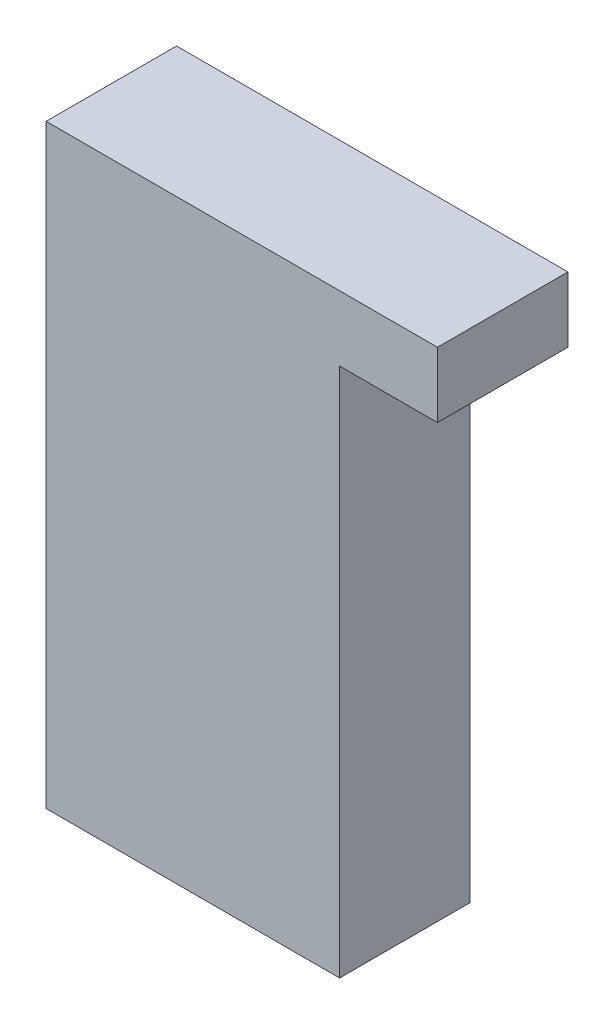
from build123d import *

# Parameters (mm, degrees)
SKETCH1_W           = 36
SKETCH1_H           = 16
BOSS_EXTRUDE1_DEPTH = 73
SKETCH2_W           = 16
SKETCH2_H           = 8
BOSS_EXTRUDE2_DEPTH = 12


with BuildPart() as part:
    # Sketch1 → Boss-Extrude1 (new body)
    with BuildSketch(Plane(origin=(0, 0, 0), x_dir=(1, 0, 0), z_dir=(0, 1, 0))):
        Rectangle(SKETCH1_W, SKETCH1_H)
    extrude(amount=BOSS_EXTRUDE1_DEPTH)

    # Sketch2 → Boss-Extrude2 (add)
    with BuildSketch(Plane(origin=(18, 0, 0), x_dir=(0, 0, -1), z_dir=(1, 0, 0))):
        with Locations((0, 69)):
            Rectangle(SKETCH2_W, SKETCH2_H)
    extrude(amount=BOSS_EXTRUDE2_DEPTH)


solid = part.part
